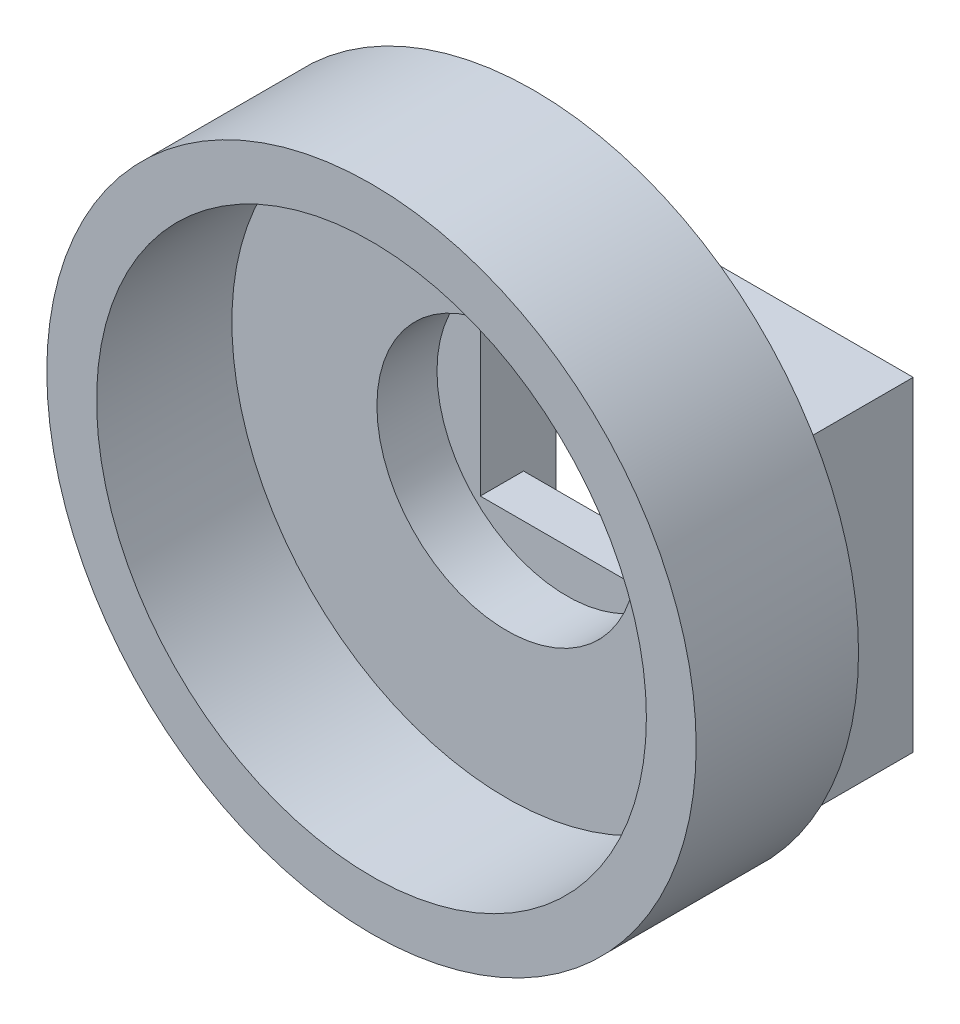
from build123d import *

# Parameters (mm, degrees)
SKETCH1_W                     = 25
SKETCH1_H                     = 15
BOSS_EXTRUDE1_DEPTH           = 5.026
M2_TAPPED_HOLE1_D             = 1.6
M2_TAPPED_HOLE1_DEPTH         = 3.5
M2_TAPPED_HOLE1_TIP           = 0.480688495
SKETCH5_R                     = 15
BOSS_EXTRUDE2_DEPTH           = 7.5
SKETCH6_R                     = 12.25
CUT_EXTRUDE1_DEPTH            = 5.25
F_1_1_8_12_TAPPED_HOLE2_D     = 25.4
F_1_1_8_12_TAPPED_HOLE2_DEPTH = 6.25
CUT_EXTRUDE2_DEPTH            = 3.5
SKETCH14_W                    = 8
SKETCH14_H                    = 1.5
CUT_EXTRUDE3_DEPTH            = 13.5
SKETCH15_R                    = 6
CUT_EXTRUDE4_DEPTH            = 13.5


with BuildPart() as part:
    # Sketch1 → Boss-Extrude1 (new body)
    with BuildSketch(Plane.XY):
        with Locations((12.5, 7.5)):
            Rectangle(SKETCH1_W, SKETCH1_H)
    extrude(amount=BOSS_EXTRUDE1_DEPTH)

    # M2 Tapped Hole1
    with Locations(Plane(origin=(0, 0, 0), x_dir=(-1, 0, 0), z_dir=(0, 0, -1))):
        with Locations((-23, 7.5), (-2, 7.5)):
            Hole(M2_TAPPED_HOLE1_D / 2, depth=M2_TAPPED_HOLE1_DEPTH)
            with Locations((0, 0, -(M2_TAPPED_HOLE1_DEPTH + M2_TAPPED_HOLE1_TIP / 2))):  # 118° drill point
                Cone(0, M2_TAPPED_HOLE1_D / 2, M2_TAPPED_HOLE1_TIP, mode=Mode.SUBTRACT)

    # Sketch5 → Boss-Extrude2 (add)
    with BuildSketch(Plane.XY.offset(5.026)):
        with Locations((12.5, 7.75)):
            Circle(SKETCH5_R)
    extrude(amount=BOSS_EXTRUDE2_DEPTH)

    # Sketch6 → Cut-Extrude1 (cut)
    with BuildSketch(Plane.XY.offset(12.526)):
        with Locations((12.5, 7.75)):
            Circle(SKETCH6_R)
    extrude(amount=-CUT_EXTRUDE1_DEPTH, mode=Mode.SUBTRACT)

    # 1-1/8-12 Tapped Hole2
    with Locations(Plane.XY.offset(12.526)):
        with Locations((12.5, 7.75)):
            Hole(F_1_1_8_12_TAPPED_HOLE2_D / 2, depth=F_1_1_8_12_TAPPED_HOLE2_DEPTH)

    # Sketch13 → Cut-Extrude2 (cut)
    with BuildSketch(Plane(origin=(0, 0, 0), x_dir=(-1, 0, 0), z_dir=(0, 0, -1))):
        Polygon((-12.5, 3.75), (-12.5, 7.5), (-12.5, 7.75), (-12.5, 11.75), (-16.5, 11.75), (-16.5, 3.75), align=None)
        Polygon((-12.5, 7.75), (-12.5, 7.5), (-12.5, 3.75), (-8.5, 3.75), (-8.5, 11.75), (-12.5, 11.75), align=None)
    extrude(amount=-CUT_EXTRUDE2_DEPTH, mode=Mode.SUBTRACT)

    # Sketch14 → Cut-Extrude3 (cut)
    with BuildSketch(Plane(origin=(0, 3.75, 0), x_dir=(1, 0, 0), z_dir=(0, 1, 0))):
        with Locations((12.5, -0.75)):
            Rectangle(SKETCH14_W, SKETCH14_H)
    extrude(amount=-CUT_EXTRUDE3_DEPTH, mode=Mode.SUBTRACT)

    # Sketch15 → Cut-Extrude4 (cut)
    with BuildSketch(Plane(origin=(0, 0, 3.5), x_dir=(-1, 0, 0), z_dir=(0, 0, -1))):
        with Locations((-12.5, 7.75)):
            Circle(SKETCH15_R)
    extrude(amount=-CUT_EXTRUDE4_DEPTH, mode=Mode.SUBTRACT)


solid = part.part
